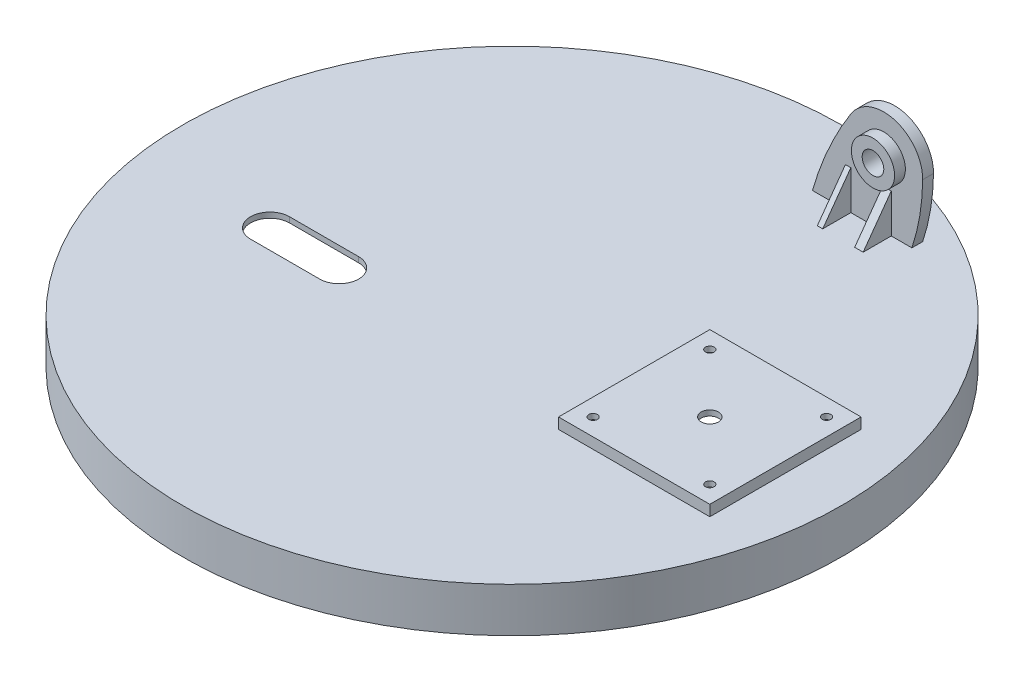
from build123d import *

# Parameters (mm, degrees)
SKETCH_1_R          = 305
EXTRUDE_1_DEPTH     = 41.2
SKETCH_2_W          = 140
SKETCH_2_H          = 140
EXTRUDE_2_DEPTH     = 10
SHELL_1_T           = -5
CUT_EXTRUDE_1_DEPTH = 434.298326791
SKETCH_4_W          = 120
SKETCH_4_H          = 10
EXTRUDE_3_DEPTH     = 150
CUT_EXTRUDE_3_DEPTH = 150
SKETCH_6_R          = 10
CUT_EXTRUDE_4_DEPTH = 150
SKETCH_7_R          = 20
SKETCH_7_R_2        = 10
EXTRUDE_4_DEPTH     = 10
SKETCH_8_W          = 5
SKETCH_8_H          = 36
SKETCH_8_W_2        = 7.838760884
EXTRUDE_5_DEPTH     = 26
CUT_EXTRUDE_5_DEPTH = 535.481627176
SKETCH_11_W         = 19
SKETCH_11_H         = 5
SKETCH_11_W_2       = 5
SKETCH_11_H_2       = 46.5
SKETCH_18_R         = 4
SKETCH_18_R_2       = 8
CUT_EXTRUDE_9_DEPTH = 440.824965185


with BuildPart() as part:
    # 草图1 → 凸台-拉伸1 (new body)
    with BuildSketch(Plane(origin=(0, 0, 0), x_dir=(1, 0, 0), z_dir=(0, 1, 0))):
        with Locations(Location((0, 0, 0), (0, 0, 90))):
            Circle(SKETCH_1_R)
    extrude(amount=EXTRUDE_1_DEPTH)

    # 草图2 → 凸台-拉伸2 (add)
    with BuildSketch(Plane(origin=(0, 41.2, 0), x_dir=(1, 0, 0), z_dir=(0, 1, 0))):
        with Locations((183, 0)):
            Rectangle(SKETCH_2_W, SKETCH_2_H)
    extrude(amount=EXTRUDE_2_DEPTH)

    # 抽壳1
    shell_1_openings = [part.faces().sort_by_distance(p)[0] for p in [
        (0, 0, 0),
    ]]
    offset(amount=SHELL_1_T, openings=shell_1_openings, kind=Kind.INTERSECTION)

    # 草图3 → 切除-拉伸1 (cut, through all)
    with BuildSketch(Plane(origin=(0, 41.2, 0), x_dir=(1, 0, 0), z_dir=(0, 1, 0))):
        with BuildLine():
            Line((-182, -24), (-118, -24))
            ThreePointArc((-118, -24), (-100, -42), (-118, -60))
            Line((-118, -60), (-182, -60))
            ThreePointArc((-182, -60), (-200, -42), (-182, -24))
        make_face()
    extrude(amount=-CUT_EXTRUDE_1_DEPTH, mode=Mode.SUBTRACT)

    # 草图4 → 凸台-拉伸3 (add)
    with BuildSketch(Plane(origin=(0, 41.2, 0), x_dir=(1, 0, 0), z_dir=(0, 1, 0))):
        with Locations((99, 244)):
            Rectangle(SKETCH_4_W, SKETCH_4_H)
    extrude(amount=EXTRUDE_3_DEPTH)

    # 草图5 → 切除-拉伸3 (cut)
    with BuildSketch(Plane.XY.offset(-239)):
        with BuildLine():
            Line((39, 191.2), (39, 41.2))
            ThreePointArc((39, 41.2), (53.931588882, 82.177347592), (74.646786984, 120.556716136))
            ThreePointArc((74.646786984, 120.556716136), (115.26317996, 135.706044936), (140.99801314, 100.821780537))
            ThreePointArc((140.99801314, 100.821780537), (138.32356193, 70.621084147), (131, 41.2))
            Line((131, 41.2), (159, 41.2))
            Line((159, 41.2), (159, 191.2))
            Line((159, 191.2), (39, 191.2))
        make_face()
    extrude(amount=-CUT_EXTRUDE_3_DEPTH, mode=Mode.SUBTRACT)

    # 草图6 → 切除-拉伸4 (cut)
    with BuildSketch(Plane.XY.offset(-239)):
        with Locations((105, 101.2)):
            Circle(SKETCH_6_R)
    extrude(amount=-CUT_EXTRUDE_4_DEPTH, mode=Mode.SUBTRACT)

    # 草图7 → 凸台-拉伸4 (add)
    with BuildSketch(Plane.XY.offset(-239)):
        with Locations(Location((105, 101.2, 0), (0, 0, 180))):
            Circle(SKETCH_7_R)
        with Locations((105, 101.2)):
            Circle(SKETCH_7_R_2, mode=Mode.SUBTRACT)
    extrude(amount=EXTRUDE_4_DEPTH)

    # 草图8 → 凸台-拉伸5 (add)
    with BuildSketch(Plane.XY.offset(-239)):
        with Locations((72, 59.2)):
            Rectangle(SKETCH_8_W, SKETCH_8_H)
        with Locations((108, 59.2)):
            Rectangle(SKETCH_8_W_2, SKETCH_8_H)
    extrude(amount=EXTRUDE_5_DEPTH)

    # 草图10 → 切除-拉伸5 (cut, through all)
    with BuildSketch(Plane(origin=(111.919380442, 0, 0), x_dir=(0, 0, -1), z_dir=(1, 0, 0))):
        Polygon((213, 41.2), (239, 77.2), (213, 77.2), align=None)
    extrude(amount=-CUT_EXTRUDE_5_DEPTH, mode=Mode.SUBTRACT)

    # 草图11 → 旋转1 (revolve)
    with BuildSketch(Plane.XY, mode=Mode.PRIVATE) as revolve_1_sk:
        with Locations((-65.5, 33.7)):
            Rectangle(SKETCH_11_W, SKETCH_11_H)
        with Locations((-82.5, 12.95)):
            Rectangle(SKETCH_11_W_2, SKETCH_11_H_2)
    revolve(revolve_1_sk.sketch.rotate(Axis((0, 0, 0), (0, 1, 0)), 270), axis=Axis((0, 0, 0), (0, 1, 0)))

    # 草图18 → 切除-拉伸9 (cut, through all)
    with BuildSketch(Plane(origin=(0, 51.2, 0), x_dir=(1, 0, 0), z_dir=(0, 1, 0))):
        with Locations(Location((237, 54, 0), (0, 0, 270))):
            Circle(SKETCH_18_R)
        with Locations(Location((237, -54, 0), (0, 0, 270))):
            Circle(SKETCH_18_R)
        with Locations(Location((129, -54, 0), (0, 0, 270))):
            Circle(SKETCH_18_R)
        with Locations(Location((129, 54, 0), (0, 0, 270))):
            Circle(SKETCH_18_R)
        with Locations(Location((183, 0, 0), (0, 0, 270))):
            Circle(SKETCH_18_R_2)
    extrude(amount=-CUT_EXTRUDE_9_DEPTH, mode=Mode.SUBTRACT)


solid = part.part
